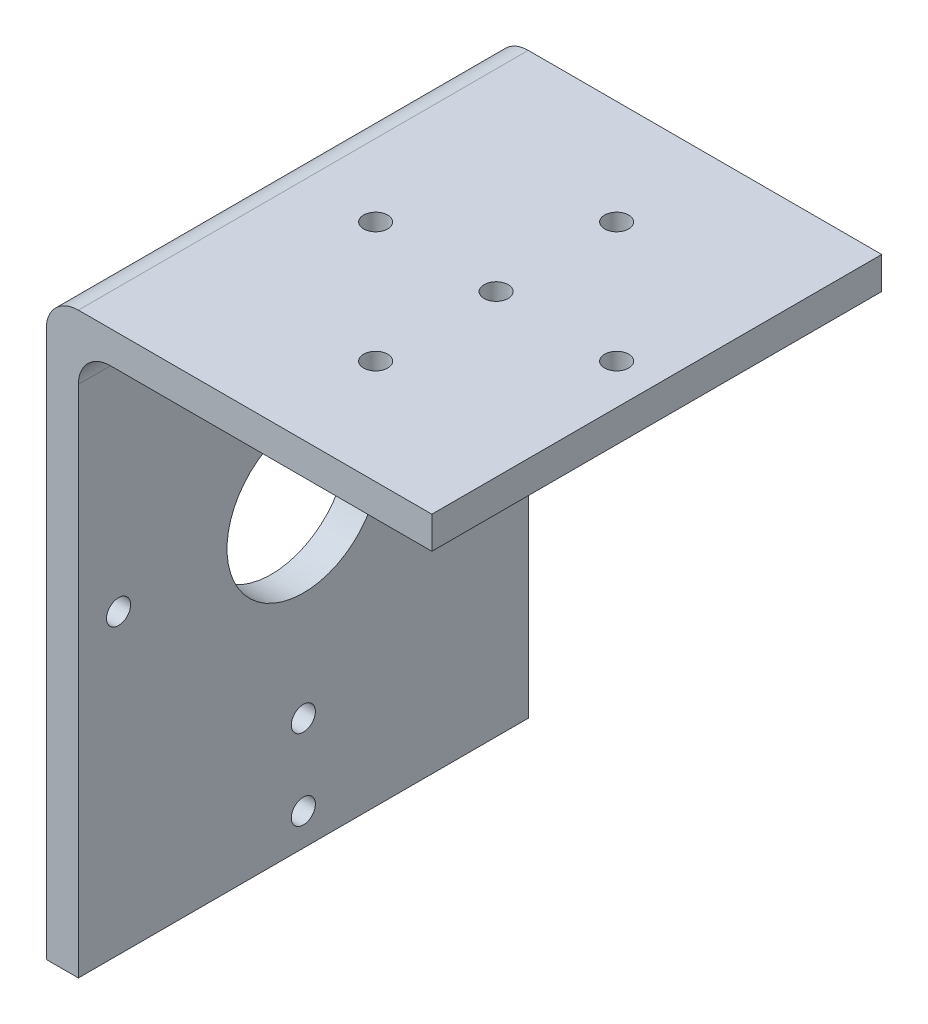
from build123d import *

# Parameters (mm, degrees)
BOSS_EXTRUDE1_DEPTH      = 28
BOSS_EXTRUDE1_DEPTH_BACK = 28
SKETCH3_R                = 9.5
SKETCH3_R_2              = 1.5
CUT_EXTRUDE1_DEPTH       = 4
FILLET2_R                = 4
SKETCH4_R                = 1.5
CUT_EXTRUDE2_DEPTH       = 4


with BuildPart() as part:
    # Sketch2 → Boss-Extrude1 (new body, two sides)
    with BuildSketch(Plane.XY) as boss_extrude1_sk:
        Polygon((-30.306244844, -59.398325359), (-26.306244844, -59.398325359), (-26.306244844, 8.601674641), (17.693755156, 8.601674641), (17.693755156, 12.601674641), (-30.306244844, 12.601674641), align=None)
    extrude(amount=BOSS_EXTRUDE1_DEPTH)
    extrude(boss_extrude1_sk.sketch, amount=-BOSS_EXTRUDE1_DEPTH_BACK)

    # Sketch3 → Cut-Extrude1 (cut)
    with BuildSketch(Plane(origin=(-26.306244844, 0, 0), x_dir=(0, 0, -1), z_dir=(1, 0, 0))):
        with Locations((0, -22.398325359)):
            Circle(SKETCH3_R)
        with Locations((0, 0.601674641)):
            Circle(SKETCH3_R_2)
        with Locations((23, -22.398325359)):
            Circle(SKETCH3_R_2)
        with Locations((0, -45.398325359)):
            Circle(SKETCH3_R_2)
        with Locations((-23, -22.398325359)):
            Circle(SKETCH3_R_2)
        with Locations((0, -55.398325359)):
            Circle(SKETCH3_R_2)
    extrude(amount=-CUT_EXTRUDE1_DEPTH, mode=Mode.SUBTRACT)

    # Fillet2
    fillet2_edges = [part.edges().sort_by_distance(p)[0] for p in [
        (-30.306244844, 12.601674641, 0),
        (-26.306244844, 8.601674641, 0),
    ]]
    fillet(fillet2_edges, radius=FILLET2_R)

    # Sketch4 → Cut-Extrude2 (cut)
    with BuildSketch(Plane.XZ.offset(-8.601674641)):
        with Locations((-2.306244844, 0)):
            Circle(SKETCH4_R)
        with Locations((-17.306244844, 0)):
            Circle(SKETCH4_R)
        with Locations((-2.306244844, 15)):
            Circle(SKETCH4_R)
        with Locations((12.693755156, 0)):
            Circle(SKETCH4_R)
        with Locations((-2.306244844, -15)):
            Circle(SKETCH4_R)
    extrude(amount=-CUT_EXTRUDE2_DEPTH, mode=Mode.SUBTRACT)


solid = part.part
